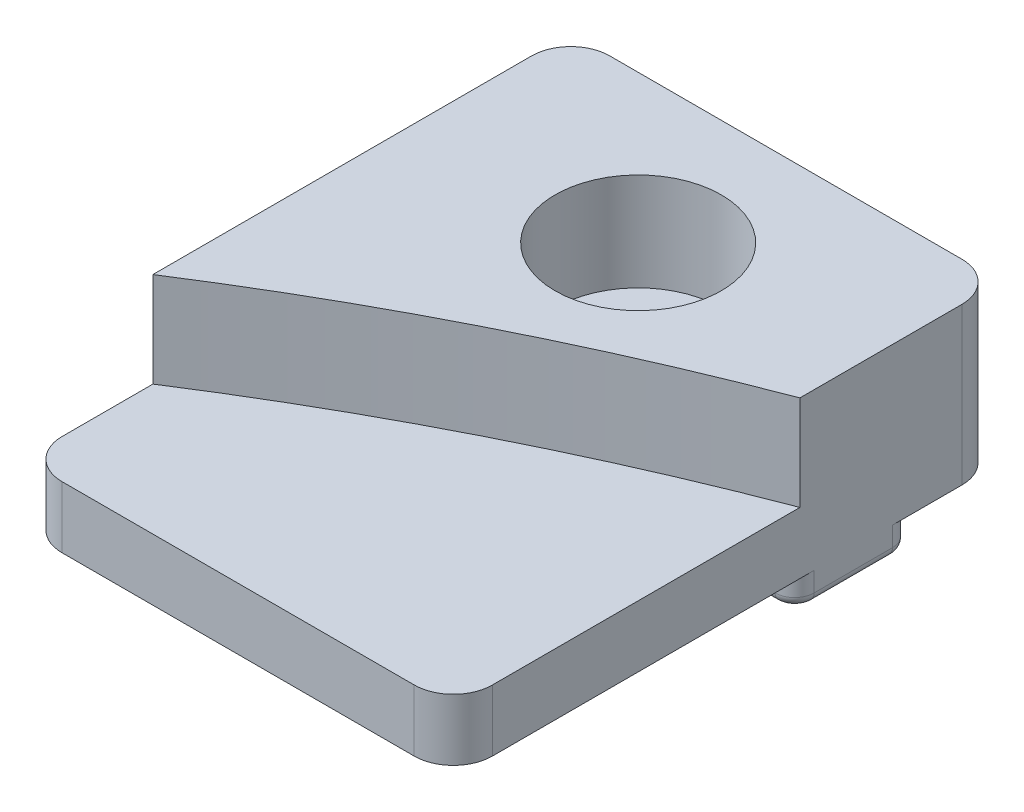
from build123d import *

# Parameters (mm, degrees)
SKETCH1_W                                        = 22
SKETCH1_H                                        = 28
BOSS_EXTRUDE1_DEPTH                              = 9.5
SKETCH2_W                                        = 17.45
SKETCH2_H                                        = 1.5
CUT_EXTRUDE1_DEPTH                               = 23
CUT_EXTRUDE2_DEPTH                               = 4.85
SKETCH4_W                                        = 4.55
SKETCH4_H                                        = 1.5
CUT_EXTRUDE3_DEPTH                               = 23
CBORE_FOR_M4_HEX_HEAD_MACHINE_SCREW1_D           = 4.3
CBORE_FOR_M4_HEX_HEAD_MACHINE_SCREW1_DEPTH       = 9.5
CBORE_FOR_M4_HEX_HEAD_MACHINE_SCREW1_CBORE_D     = 8.5
CBORE_FOR_M4_HEX_HEAD_MACHINE_SCREW1_CBORE_DEPTH = 5
FILLET1_R                                        = 1
FILLET2_R                                        = 0.5
FILLET3_R                                        = 2


with BuildPart() as part:
    # Sketch1 → Boss-Extrude1 (new body)
    with BuildSketch(Plane(origin=(0, 8, 0), x_dir=(1, 0, 0), z_dir=(0, 1, 0))):
        Rectangle(SKETCH1_W, SKETCH1_H)
    extrude(amount=-BOSS_EXTRUDE1_DEPTH)

    # Sketch2 → Cut-Extrude1 (cut, through all)
    with BuildSketch(Plane(origin=(11, 0, 0), x_dir=(0, 0, -1), z_dir=(1, 0, 0))):
        with Locations((-5.275, -0.75)):
            Rectangle(SKETCH2_W, SKETCH2_H)
    extrude(amount=-CUT_EXTRUDE1_DEPTH, mode=Mode.SUBTRACT)

    # Sketch3 → Cut-Extrude2 (cut)
    with BuildSketch(Plane(origin=(0, 8, 0), x_dir=(-1, 0, 0), z_dir=(0, 1, 0))):
        with BuildLine():
            Line((11, 7.358592124), (11, 14))
            Line((11, 14), (-11, 14))
            Line((-11, 14), (-11, -3.718814308))
            ThreePointArc((-11, -3.718814308), (0.2873816, 1.249142024), (11, 7.358592124))
        make_face()
    extrude(amount=-CUT_EXTRUDE2_DEPTH, mode=Mode.SUBTRACT)

    # Sketch4 → Cut-Extrude3 (cut, through all)
    with BuildSketch(Plane(origin=(11, 0, 0), x_dir=(0, 0, -1), z_dir=(1, 0, 0))):
        with Locations((11.725, -0.75)):
            Rectangle(SKETCH4_W, SKETCH4_H)
    extrude(amount=-CUT_EXTRUDE3_DEPTH, mode=Mode.SUBTRACT)

    # CBORE for M4 Hex Head Machine Screw1
    with Locations(Plane(origin=(0, 8, 0), x_dir=(1, 0, 0), z_dir=(0, 1, 0))):
        with Locations((0, 6.45)):
            CounterBoreHole(CBORE_FOR_M4_HEX_HEAD_MACHINE_SCREW1_D / 2, CBORE_FOR_M4_HEX_HEAD_MACHINE_SCREW1_CBORE_D / 2, CBORE_FOR_M4_HEX_HEAD_MACHINE_SCREW1_CBORE_DEPTH, depth=CBORE_FOR_M4_HEX_HEAD_MACHINE_SCREW1_DEPTH)

    # Fillet1
    fillet1_edges = [part.edges().sort_by_distance(p)[0] for p in [
        (-11, -0.75, -3.45),
        (11, -0.75, -3.45),
        (-11, -0.75, -9.45),
        (11, -0.75, -9.45),
    ]]
    fillet(fillet1_edges, radius=FILLET1_R)

    # Fillet2
    fillet2_edges = [part.edges().sort_by_distance(p)[0] for p in [
        (0, -1.5, -3.45),
        (11, -1.5, -6.45),
        (-11, -1.5, -6.45),
        (0, -1.5, -9.45),
        (-10.707106781, -1.5, -9.157106781),
        (10.707106781, -1.5, -9.157106781),
        (-10.707106781, -1.5, -3.742893219),
        (10.707106781, -1.5, -3.742893219),
    ]]
    fillet(fillet2_edges, radius=FILLET2_R)

    # Fillet3
    fillet3_edges = [part.edges().sort_by_distance(p)[0] for p in [
        (11, 1.575, 14),
        (-11, 1.575, 14),
        (11, 4, -14),
        (-11, 4, -14),
    ]]
    fillet(fillet3_edges, radius=FILLET3_R)


solid = part.part
